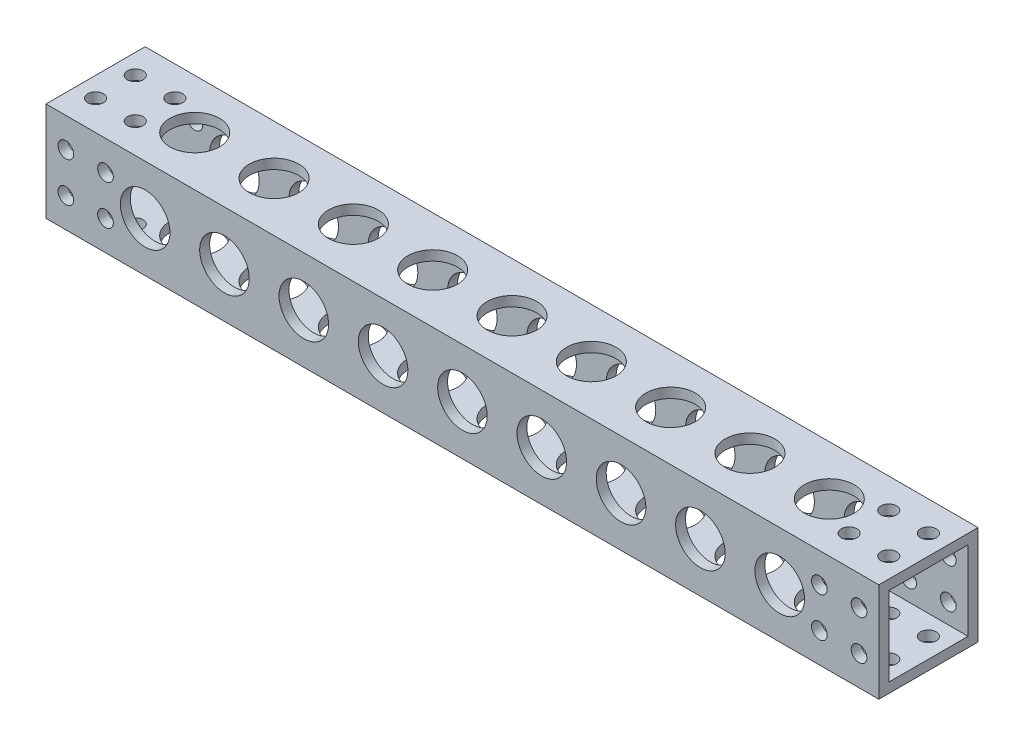
from build123d import *

# Parameters (mm, degrees)
SKETCH1_W           = 266.7
SKETCH1_H           = 31.75
BOSS_EXTRUDE1_DEPTH = 31.75
SKETCH2_R           = 7.9375
CUT_EXTRUDE1_DEPTH  = 31.75
LPATTERN1_COUNT     = 9
LPATTERN1_PITCH     = 25.4
SKETCH3_R           = 2.50825
CUT_EXTRUDE2_DEPTH  = 31.75
SKETCH4_W           = 25.4
SKETCH4_H           = 25.4
CUT_EXTRUDE3_DEPTH  = 266.7
SKETCH5_R           = 7.9375
CUT_EXTRUDE4_DEPTH  = 31.75
LPATTERN2_COUNT     = 9
LPATTERN2_PITCH     = 25.4
SKETCH6_R           = 2.50825
CUT_EXTRUDE5_DEPTH  = 31.75


with BuildPart() as part:
    # Sketch1 → Boss-Extrude1 (new body)
    with BuildSketch(Plane.XY):
        with Locations((-133.35, -15.875)):
            Rectangle(SKETCH1_W, SKETCH1_H)
    extrude(amount=BOSS_EXTRUDE1_DEPTH)

    # Sketch2 → Cut-Extrude1 (cut)
    with BuildSketch(Plane.XY.offset(31.75)):
        with Locations((-234.95, -15.875)):
            Circle(SKETCH2_R)
    cut_extrude1 = extrude(amount=-CUT_EXTRUDE1_DEPTH, mode=Mode.SUBTRACT)

    # LPattern1: Cut-Extrude1 ×9
    with Locations(*[(i * LPATTERN1_PITCH, 0, 0) for i in range(1, LPATTERN1_COUNT)]):
        add(cut_extrude1, mode=Mode.SUBTRACT)

    # Sketch3 → Cut-Extrude2 (cut)
    with BuildSketch(Plane.XY.offset(31.75)):
        with Locations((-260.35, -9.525)):
            Circle(SKETCH3_R)
        with Locations((-247.65, -9.525)):
            Circle(SKETCH3_R)
        with Locations((-260.35, -22.225)):
            Circle(SKETCH3_R)
        with Locations((-247.65, -22.225)):
            Circle(SKETCH3_R)
    cut_extrude2 = extrude(amount=-CUT_EXTRUDE2_DEPTH, mode=Mode.SUBTRACT)

    # Sketch4 → Cut-Extrude3 (cut)
    with BuildSketch(Plane(origin=(0, 0, 0), x_dir=(0, 0, -1), z_dir=(1, 0, 0))):
        with Locations((-15.875, -15.875)):
            Rectangle(SKETCH4_W, SKETCH4_H)
    extrude(amount=-CUT_EXTRUDE3_DEPTH, mode=Mode.SUBTRACT)

    # Mirror1: Cut-Extrude2 across plane
    add(cut_extrude2.mirror(Plane(origin=(-133.35, 0, 0), x_dir=(0, 0, 1), z_dir=(1, 0, 0))), mode=Mode.SUBTRACT)

    # Sketch5 → Cut-Extrude4 (cut)
    with BuildSketch(Plane(origin=(0, 0, 0), x_dir=(1, 0, 0), z_dir=(0, 1, 0))):
        with Locations((-31.75, -15.875)):
            Circle(SKETCH5_R)
    cut_extrude4 = extrude(amount=-CUT_EXTRUDE4_DEPTH, mode=Mode.SUBTRACT)

    # LPattern2: Cut-Extrude4 ×9
    with Locations(*[(-i * LPATTERN2_PITCH, 0, 0) for i in range(1, LPATTERN2_COUNT)]):
        add(cut_extrude4, mode=Mode.SUBTRACT)

    # Sketch6 → Cut-Extrude5 (cut)
    with BuildSketch(Plane(origin=(0, 0, 0), x_dir=(1, 0, 0), z_dir=(0, 1, 0))):
        with Locations((-19.05, -9.525)):
            Circle(SKETCH6_R)
        with Locations((-6.35, -9.525)):
            Circle(SKETCH6_R)
        with Locations((-19.05, -22.225)):
            Circle(SKETCH6_R)
        with Locations((-6.35, -22.225)):
            Circle(SKETCH6_R)
    cut_extrude5 = extrude(amount=-CUT_EXTRUDE5_DEPTH, mode=Mode.SUBTRACT)

    # Mirror2: Cut-Extrude5 across plane
    add(cut_extrude5.mirror(Plane(origin=(-133.35, 0, 0), x_dir=(0, 0, 1), z_dir=(1, 0, 0))), mode=Mode.SUBTRACT)


solid = part.part
